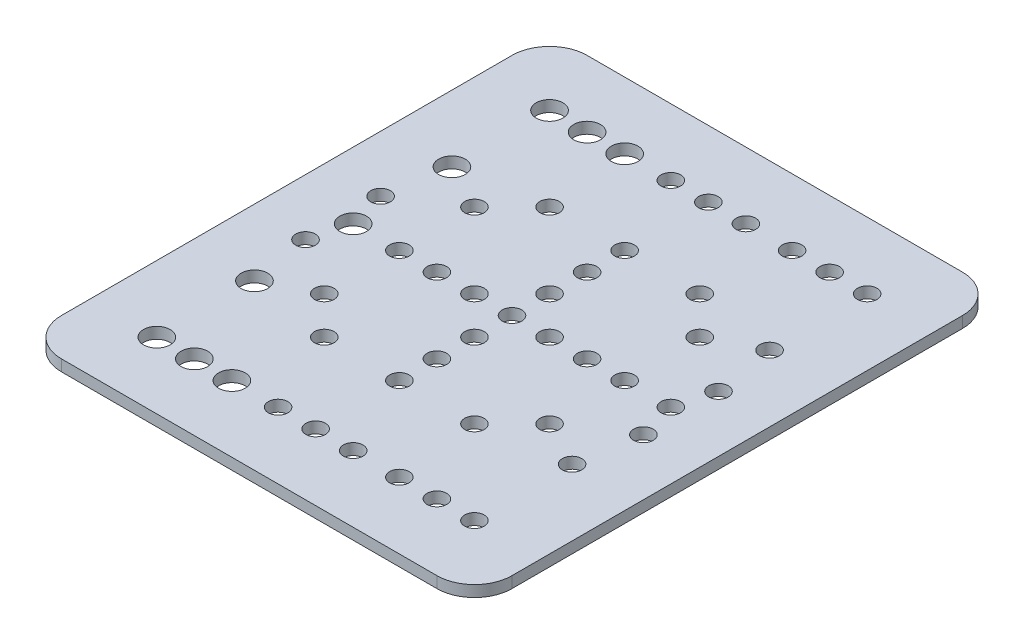
from build123d import *

# Parameters (mm, degrees)
SKETCH1_R           = 3.55
SKETCH1_R_2         = 2.6
BOSS_EXTRUDE1_DEPTH = 3


with BuildPart() as part:
    # Sketch1 → Boss-Extrude1 (new body)
    with BuildSketch(Plane(origin=(0, 0, 0), x_dir=(1, 0, 0), z_dir=(0, 1, 0))):
        with BuildLine():
            Line((50, -70), (-50, -70))
            ThreePointArc((-50, -70), (-57.071067812, -67.071067812), (-60, -60))
            Line((-60, -60), (-60, 60))
            ThreePointArc((-60, 60), (-57.071067812, 67.071067812), (-50, 70))
            Line((-50, 70), (50, 70))
            ThreePointArc((50, 70), (57.071067812, 67.071067812), (60, 60))
            Line((60, 60), (60, -60))
            ThreePointArc((60, -60), (57.071067812, -67.071067812), (50, -70))
        make_face()
        with Locations((-32.3, 52.3)):
            Circle(SKETCH1_R, mode=Mode.SUBTRACT)
        with Locations((0, 10)):
            Circle(SKETCH1_R_2, mode=Mode.SUBTRACT)
        Circle(SKETCH1_R_2, mode=Mode.SUBTRACT)
        with Locations((10, 0)):
            Circle(SKETCH1_R_2, mode=Mode.SUBTRACT)
        with Locations((-10, 0)):
            Circle(SKETCH1_R_2, mode=Mode.SUBTRACT)
        with Locations((-42.3, 52.3)):
            Circle(SKETCH1_R, mode=Mode.SUBTRACT)
        with Locations((-42.3, 0)):
            Circle(SKETCH1_R, mode=Mode.SUBTRACT)
        with Locations((-42.3, -52.3)):
            Circle(SKETCH1_R, mode=Mode.SUBTRACT)
        with Locations((-30, 20)):
            Circle(SKETCH1_R_2, mode=Mode.SUBTRACT)
        with Locations((-45, 10)):
            Circle(SKETCH1_R_2, mode=Mode.SUBTRACT)
        with Locations((-20, 30)):
            Circle(SKETCH1_R_2, mode=Mode.SUBTRACT)
        with Locations((0, 20)):
            Circle(SKETCH1_R_2, mode=Mode.SUBTRACT)
        with Locations((-10, 52.3)):
            Circle(SKETCH1_R_2, mode=Mode.SUBTRACT)
        with Locations((0, 52.3)):
            Circle(SKETCH1_R_2, mode=Mode.SUBTRACT)
        with Locations((10, 52.3)):
            Circle(SKETCH1_R_2, mode=Mode.SUBTRACT)
        with Locations((0, 30)):
            Circle(SKETCH1_R_2, mode=Mode.SUBTRACT)
        with Locations((20, 30)):
            Circle(SKETCH1_R_2, mode=Mode.SUBTRACT)
        with Locations((30, 20)):
            Circle(SKETCH1_R_2, mode=Mode.SUBTRACT)
        with Locations((45, 10)):
            Circle(SKETCH1_R_2, mode=Mode.SUBTRACT)
        with Locations((32.3, 52.3)):
            Circle(SKETCH1_R_2, mode=Mode.SUBTRACT)
        with Locations((42.3, 52.3)):
            Circle(SKETCH1_R_2, mode=Mode.SUBTRACT)
        with Locations((42.3, 0)):
            Circle(SKETCH1_R_2, mode=Mode.SUBTRACT)
        with Locations((45, -10)):
            Circle(SKETCH1_R_2, mode=Mode.SUBTRACT)
        with Locations((42.3, -52.3)):
            Circle(SKETCH1_R_2, mode=Mode.SUBTRACT)
        with Locations((32.3, -52.3)):
            Circle(SKETCH1_R_2, mode=Mode.SUBTRACT)
        with Locations((30, -20)):
            Circle(SKETCH1_R_2, mode=Mode.SUBTRACT)
        with Locations((0, -10)):
            Circle(SKETCH1_R_2, mode=Mode.SUBTRACT)
        with Locations((20, -30)):
            Circle(SKETCH1_R_2, mode=Mode.SUBTRACT)
        with Locations((20, 0)):
            Circle(SKETCH1_R_2, mode=Mode.SUBTRACT)
        with Locations((10, -52.3)):
            Circle(SKETCH1_R_2, mode=Mode.SUBTRACT)
        with Locations((0, -52.3)):
            Circle(SKETCH1_R_2, mode=Mode.SUBTRACT)
        with Locations((-10, -52.3)):
            Circle(SKETCH1_R_2, mode=Mode.SUBTRACT)
        with Locations((30, 0)):
            Circle(SKETCH1_R_2, mode=Mode.SUBTRACT)
        with Locations((-20, -30)):
            Circle(SKETCH1_R_2, mode=Mode.SUBTRACT)
        with Locations((-30, -20)):
            Circle(SKETCH1_R_2, mode=Mode.SUBTRACT)
        with Locations((-45, -10)):
            Circle(SKETCH1_R_2, mode=Mode.SUBTRACT)
        with Locations((-32.3, -52.3)):
            Circle(SKETCH1_R, mode=Mode.SUBTRACT)
        with Locations((-22.3, 52.3)):
            Circle(SKETCH1_R, mode=Mode.SUBTRACT)
        with Locations((22.3, 52.3)):
            Circle(SKETCH1_R_2, mode=Mode.SUBTRACT)
        with Locations((-20, 0)):
            Circle(SKETCH1_R_2, mode=Mode.SUBTRACT)
        with Locations((-30, 0)):
            Circle(SKETCH1_R_2, mode=Mode.SUBTRACT)
        with Locations((-42.3, 26.3)):
            Circle(SKETCH1_R, mode=Mode.SUBTRACT)
        with Locations((22.3, -52.3)):
            Circle(SKETCH1_R_2, mode=Mode.SUBTRACT)
        with Locations((-22.3, -52.3)):
            Circle(SKETCH1_R, mode=Mode.SUBTRACT)
        with Locations((-42.3, -26.3)):
            Circle(SKETCH1_R, mode=Mode.SUBTRACT)
        with Locations((42.3, 26.3)):
            Circle(SKETCH1_R_2, mode=Mode.SUBTRACT)
        with Locations((42.3, -26.3)):
            Circle(SKETCH1_R_2, mode=Mode.SUBTRACT)
        with Locations((0, -30)):
            Circle(SKETCH1_R_2, mode=Mode.SUBTRACT)
        with Locations((0, -20)):
            Circle(SKETCH1_R_2, mode=Mode.SUBTRACT)
    extrude(amount=BOSS_EXTRUDE1_DEPTH)


solid = part.part
